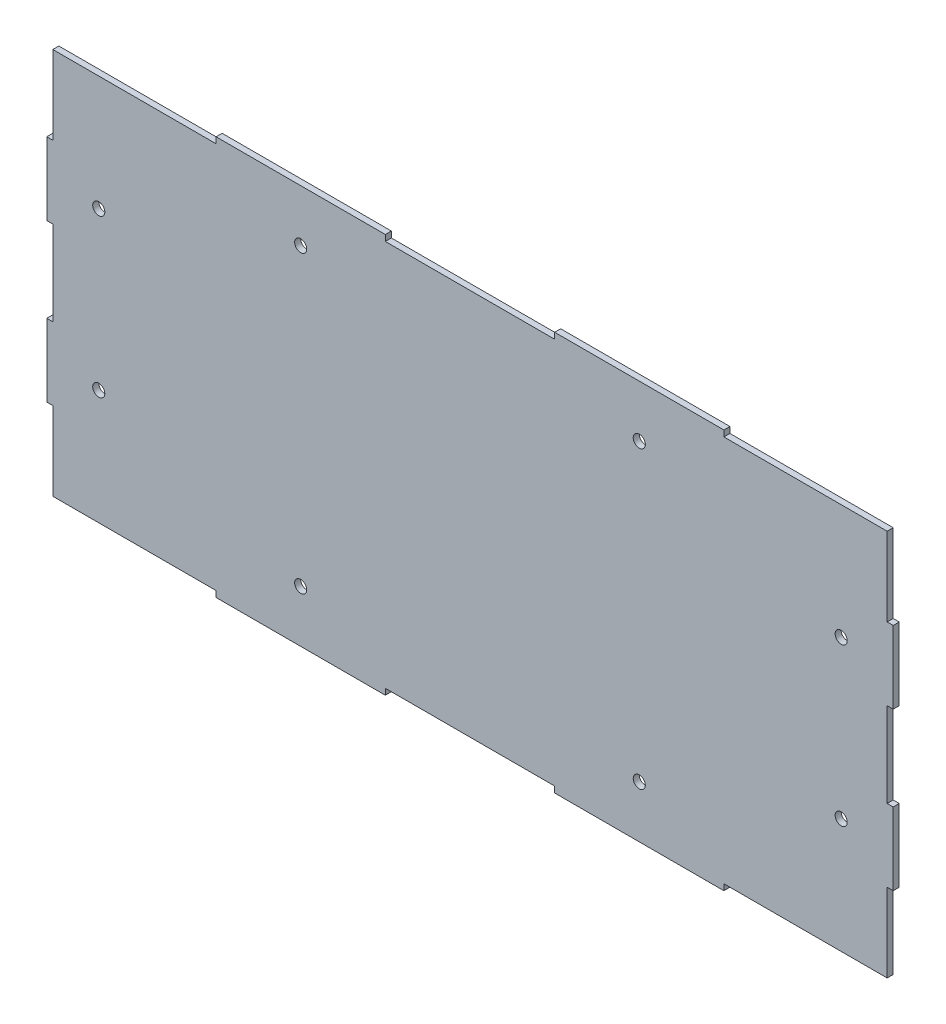
from build123d import *

# Parameters (mm, degrees)
SKETCH1_R           = 2.5
BOSS_EXTRUDE1_DEPTH = 2.5


with BuildPart() as part:
    # Sketch1 → Boss-Extrude1 (new body)
    with BuildSketch(Plane.XY):
        Polygon((-172.5, 80), (-105, 80), (-105, 82.5), (-35, 82.5), (-35, 80), (35, 80), (35, 82.5), (105, 82.5), (105, 80), (172.5, 80), (172.5, 47.5), (175, 47.5), (175, 17.5), (172.5, 17.5), (172.5, -17.5), (175, -17.5), (175, -47.5), (172.5, -47.5), (172.5, -80), (105, -80), (105, -82.5), (35, -82.5), (35, -80), (-35, -80), (-35, -82.5), (-105, -82.5), (-105, -80), (-172.5, -80), (-172.5, -47.5), (-175, -47.5), (-175, -17.5), (-172.5, -17.5), (-172.5, 17.5), (-175, 17.5), (-175, 47.5), (-172.5, 47.5), align=None)
        with Locations((-70, -61)):
            Circle(SKETCH1_R, mode=Mode.SUBTRACT)
        with Locations((70, -61)):
            Circle(SKETCH1_R, mode=Mode.SUBTRACT)
        with Locations((70, 61)):
            Circle(SKETCH1_R, mode=Mode.SUBTRACT)
        with Locations((-70, 61)):
            Circle(SKETCH1_R, mode=Mode.SUBTRACT)
        with Locations((153.5, -32.5)):
            Circle(SKETCH1_R, mode=Mode.SUBTRACT)
        with Locations((153.5, 32.5)):
            Circle(SKETCH1_R, mode=Mode.SUBTRACT)
        with Locations((-153.5, -32.5)):
            Circle(SKETCH1_R, mode=Mode.SUBTRACT)
        with Locations((-153.5, 32.5)):
            Circle(SKETCH1_R, mode=Mode.SUBTRACT)
    extrude(amount=BOSS_EXTRUDE1_DEPTH)


solid = part.part
